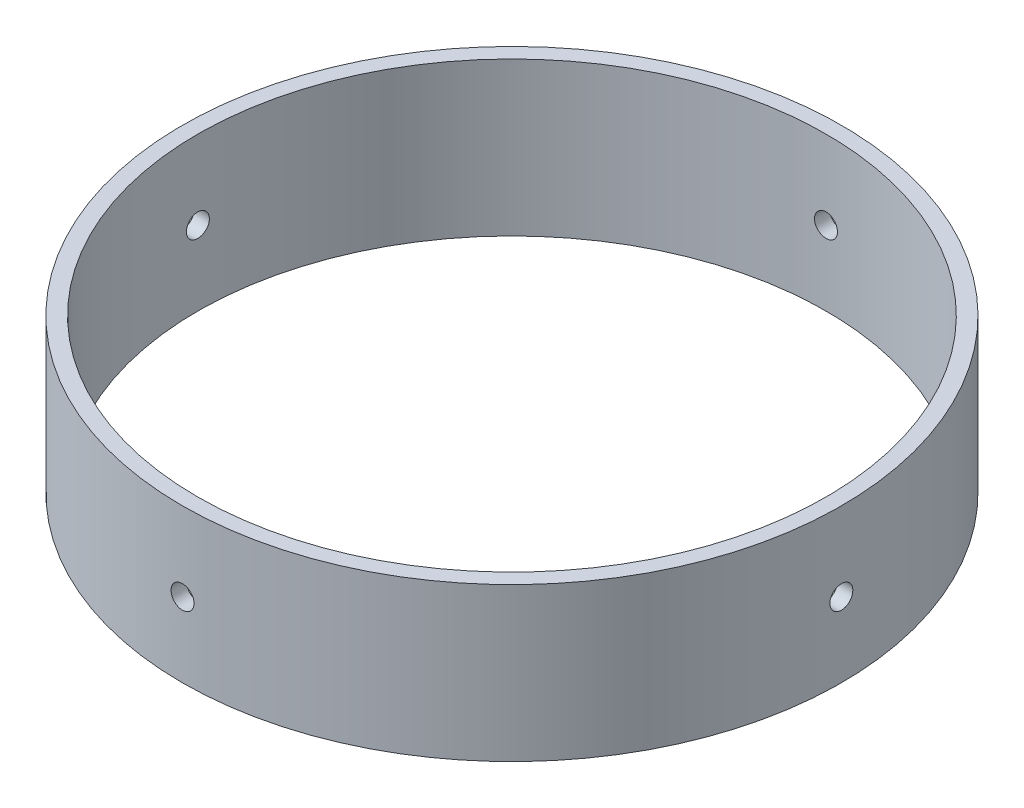
from build123d import *

# Parameters (mm, degrees)
SKETCH1_R           = 54.61
SKETCH1_R_2         = 52.07
BOSS_EXTRUDE1_DEPTH = 25.4
SKETCH3_R           = 1.905
CUT_EXTRUDE1_DEPTH  = 55.61
CIRPATTERN1_COUNT   = 4


with BuildPart() as part:
    # Sketch1 → Boss-Extrude1 (new body)
    with BuildSketch(Plane(origin=(0, 0, 0), x_dir=(1, 0, 0), z_dir=(0, 1, 0))):
        Circle(SKETCH1_R)
        Circle(SKETCH1_R_2, mode=Mode.SUBTRACT)
    extrude(amount=BOSS_EXTRUDE1_DEPTH)

    # Sketch3 → Cut-Extrude1 (cut, through all)
    with BuildSketch(Plane.XY):
        with Locations((0, 12.328955527)):
            Circle(SKETCH3_R)
    cut_extrude1 = extrude(amount=CUT_EXTRUDE1_DEPTH, mode=Mode.SUBTRACT)

    # CirPattern1: Cut-Extrude1 ×4 about axis
    cirpattern1_axis = Axis((0, 25.4, 0), (0, 1, 0))
    for i in range(1, CIRPATTERN1_COUNT):
        add(cut_extrude1.rotate(cirpattern1_axis, i * 360 / CIRPATTERN1_COUNT), mode=Mode.SUBTRACT)


solid = part.part
